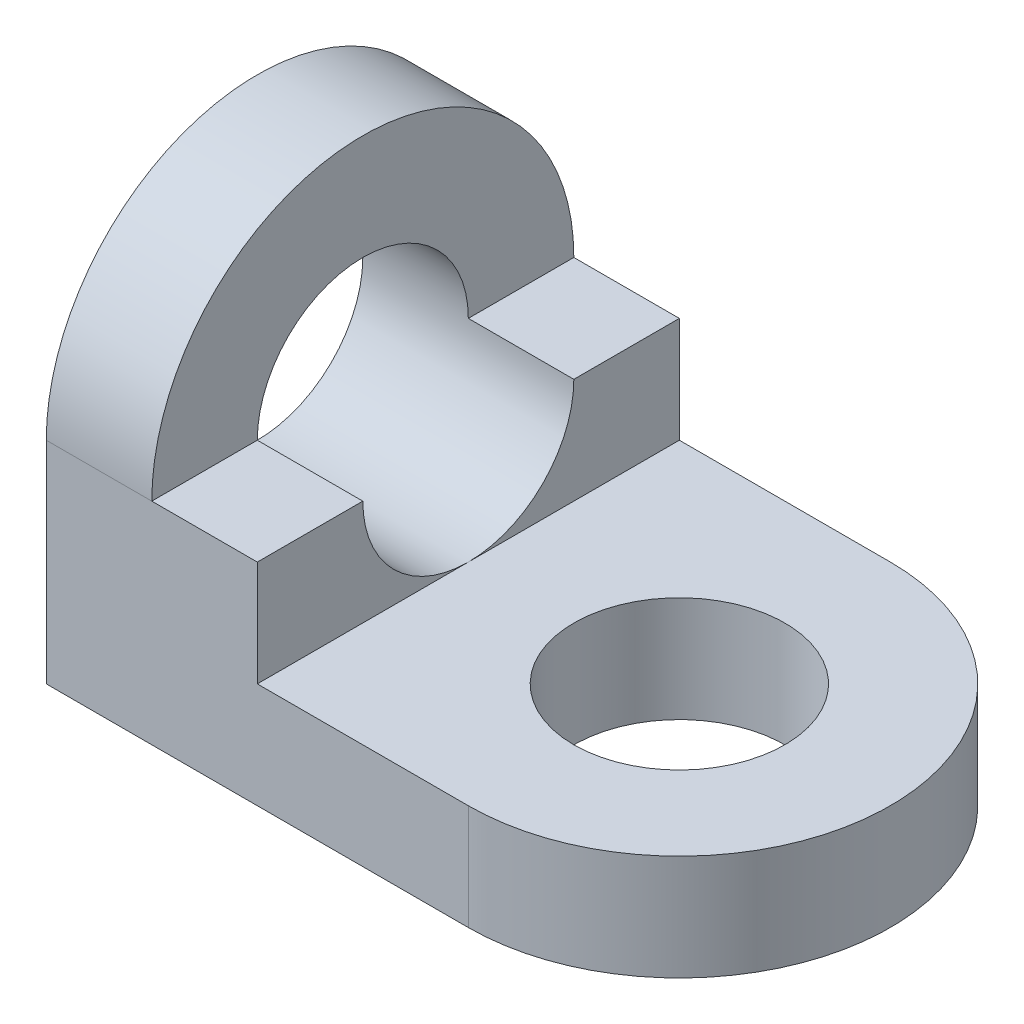
from build123d import *

# Parameters (mm, degrees)
SKETCH_1_R      = 5
EXTRUDE_1_DEPTH = 5
SKETCH_2_R      = 5
EXTRUDE_3_DEPTH = 5
EXTRUDE_4_DEPTH = 10


with BuildPart() as part:
    # 草圖1 → 填料-伸長1 (new body)
    with BuildSketch(Plane(origin=(0, 0, 0), x_dir=(1, 0, 0), z_dir=(0, 1, 0))):
        with BuildLine():
            Line((20, 10), (0, 10))
            Line((0, 10), (0, -10))
            Line((0, -10), (20, -10))
            ThreePointArc((20, -10), (30, 0), (20, 10))
        make_face()
        with Locations((20, 0)):
            Circle(SKETCH_1_R, mode=Mode.SUBTRACT)
    extrude(amount=EXTRUDE_1_DEPTH)

    # 草圖2 → 填料-伸長3 (add)
    with BuildSketch(Plane(origin=(0, 0, 0), x_dir=(0, 0, -1), z_dir=(1, 0, 0))):
        with BuildLine():
            Line((-10, 10), (-10, 0))
            Line((-10, 0), (10, 0))
            Line((10, 0), (10, 10))
            ThreePointArc((10, 10), (0, 20), (-10, 10))
        make_face()
        with Locations((0, 10)):
            Circle(SKETCH_2_R, mode=Mode.SUBTRACT)
    extrude(amount=EXTRUDE_3_DEPTH)

    # 草圖2<4> → 填料-伸長4 (add)
    with BuildSketch(Plane(origin=(0, 0, 0), x_dir=(0, 0, -1), z_dir=(1, 0, 0))):
        with BuildLine():
            Line((-5, 10), (-10, 10))
            Line((-10, 10), (-10, 0))
            Line((-10, 0), (10, 0))
            Line((10, 0), (10, 10))
            Line((10, 10), (5, 10))
            ThreePointArc((5, 10), (0, 5), (-5, 10))
        make_face()
    extrude(amount=EXTRUDE_4_DEPTH)


solid = part.part
